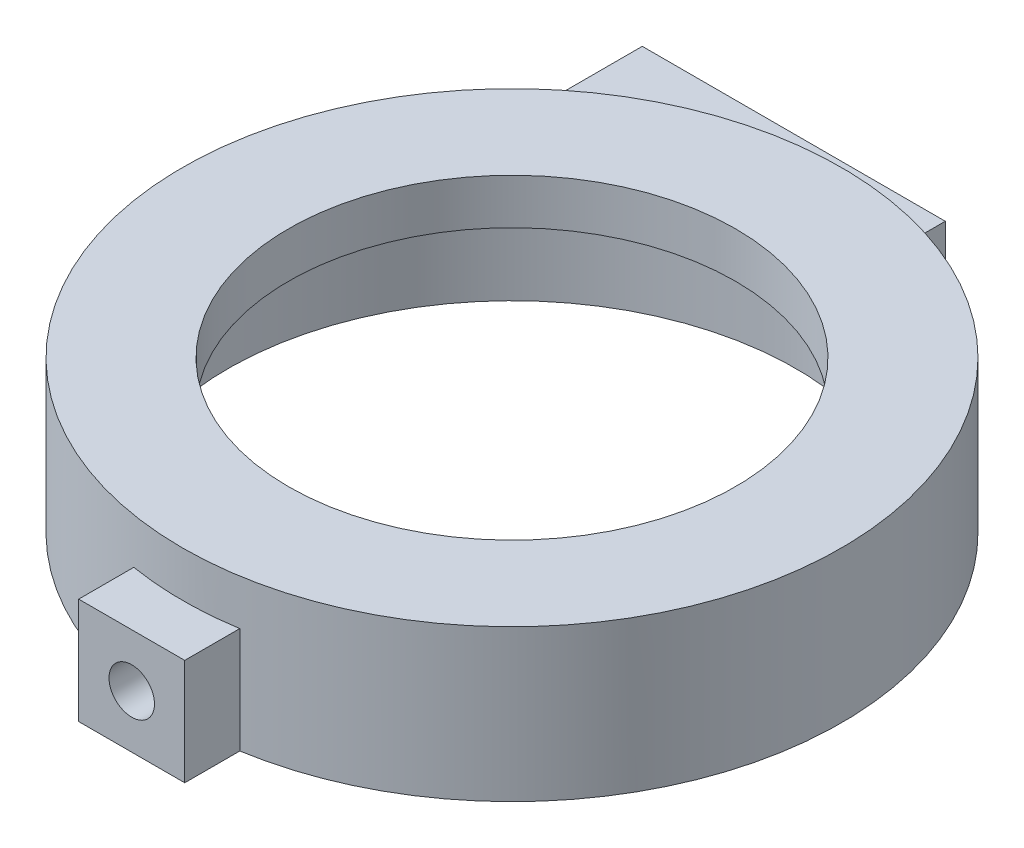
from build123d import *

# Parameters (mm, degrees)
SKETCH1_R           = 18.75
BOSS_EXTRUDE1_DEPTH = 7
SKETCH2_R           = 1.5
CUT_EXTRUDE1_DEPTH  = 7
SKETCH3_R           = 1.4
CUT_EXTRUDE2_DEPTH  = 5
BOSS_EXTRUDE3_DEPTH = 7
SKETCH7_R           = 1.4
CUT_EXTRUDE3_DEPTH  = 7
SKETCH9_R           = 21.75
SKETCH9_R_2         = 14.75
BOSS_EXTRUDE5_DEPTH = 3


with BuildPart() as part:
    # Sketch1 → Boss-Extrude1 (new body)
    with BuildSketch(Plane(origin=(0, 0, 0), x_dir=(1, 0, 0), z_dir=(0, 1, 0))):
        with BuildLine():
            Line((3.5, -25.1), (-3.5, -25.1))
            Line((-3.5, -25.1), (-3.5, -21.466544))
            ThreePointArc((-3.5, -21.466544), (-21.75, 0), (-3.5, 21.466544))
            Line((-3.5, 21.466544), (-3.5, 25.1))
            Line((-3.5, 25.1), (3.5, 25.1))
            Line((3.5, 25.1), (3.5, 21.466544))
            ThreePointArc((3.5, 21.466544), (21.75, 0), (3.5, -21.466544))
            Line((3.5, -21.466544), (3.5, -25.1))
        make_face()
        Circle(SKETCH1_R, mode=Mode.SUBTRACT)
    extrude(amount=BOSS_EXTRUDE1_DEPTH)

    # Sketch2 → Cut-Extrude1 (cut)
    with BuildSketch(Plane.XY.offset(25.1)):
        with Locations((0, 3.5)):
            Circle(SKETCH2_R)
    extrude(amount=-CUT_EXTRUDE1_DEPTH, mode=Mode.SUBTRACT)

    # Sketch3 → Cut-Extrude2 (cut)
    with BuildSketch(Plane(origin=(0, 0, -25.1), x_dir=(-1, 0, 0), z_dir=(0, 0, -1))):
        with Locations((0, 3.5)):
            Circle(SKETCH3_R)
    extrude(amount=-CUT_EXTRUDE2_DEPTH, mode=Mode.SUBTRACT)

    # Sketch6 → Boss-Extrude3 (add)
    with BuildSketch(Plane(origin=(0, 0, 0), x_dir=(-1, 0, 0), z_dir=(0, -1, 0))):
        with BuildLine():
            Line((3.5, 25.1), (16.5, 25.1))
            Line((16.5, 25.1), (16.5, 14.170833))
            ThreePointArc((16.5, 14.170833), (10.644569, 18.967226), (3.5, 21.466544))
            Line((3.5, 21.466544), (3.5, 25.1))
        make_face()
    extrude(amount=-BOSS_EXTRUDE3_DEPTH)

    # Sketch7 → Cut-Extrude3 (cut)
    with BuildSketch(Plane(origin=(0, 0, -25.1), x_dir=(-1, 0, 0), z_dir=(0, 0, -1))):
        with Locations((10, 3.5)):
            Circle(SKETCH7_R)
    extrude(amount=-CUT_EXTRUDE3_DEPTH, mode=Mode.SUBTRACT)

    # Sketch9 → Boss-Extrude5 (add)
    with BuildSketch(Plane(origin=(0, 7, 0), x_dir=(1, 0, 0), z_dir=(0, 1, 0))):
        Circle(SKETCH9_R)
        Circle(SKETCH9_R_2, mode=Mode.SUBTRACT)
    extrude(amount=BOSS_EXTRUDE5_DEPTH)


solid = part.part
